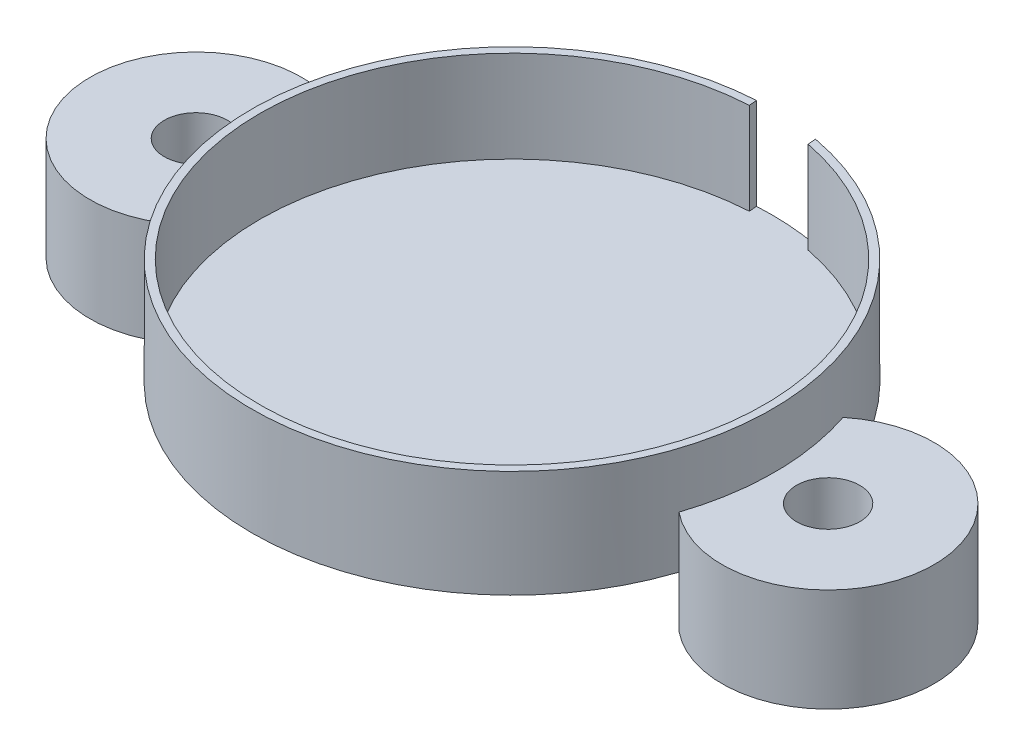
from build123d import *

# Parameters (mm, degrees)
SKETCH1_R                  = 53.2892
BOSS_EXTRUDE1_DEPTH        = 21.971
SKETCH3_R                  = 51.689
CUT_EXTRUDE2_DEPTH         = 18.796
CUT_EXTRUDE7_DEPTH         = 18.796
SKETCH7_R                  = 6.477
BOSS_EXTRUDE3_DEPTH        = 10.16
BOSS_EXTRUDE3_DEPTH_BACK   = 10.9855
BOSS_EXTRUDE3_2_DEPTH      = 10.16
BOSS_EXTRUDE3_2_DEPTH_BACK = 10.9855


with BuildPart() as part:
    # Sketch1 → Boss-Extrude1 (new body)
    with BuildSketch(Plane(origin=(0, 0, 0), x_dir=(1, 0, 0), z_dir=(0, 1, 0))):
        Circle(SKETCH1_R)
    extrude(amount=BOSS_EXTRUDE1_DEPTH)

    # Sketch3 → Cut-Extrude2 (cut)
    with BuildSketch(Plane(origin=(0, 21.971, 0), x_dir=(1, 0, 0), z_dir=(0, 1, 0))):
        Circle(SKETCH3_R)
    extrude(amount=-CUT_EXTRUDE2_DEPTH, mode=Mode.SUBTRACT)

    # Sketch6 → Cut-Extrude7 (cut)
    with BuildSketch(Plane(origin=(0, 21.971, 0), x_dir=(1, 0, 0), z_dir=(0, 1, 0))):
        with BuildLine():
            Line((9.954937367, 50.721316456), (9.791852008, 52.381852496))
            ThreePointArc((9.791852008, 52.381852496), (3.368560686, 53.182625316), (-3.104433229, 53.198696704))
            Line((-3.104433229, 53.198696704), (-2.968977791, 51.603661613))
            ThreePointArc((-2.968977791, 51.603661613), (3.520730186, 51.568955583), (9.954937367, 50.721316456))
        make_face()
    extrude(amount=-CUT_EXTRUDE7_DEPTH, mode=Mode.SUBTRACT)


with BuildPart() as body_2:
    # Sketch7 → Boss-Extrude3 (new body, two sides)
    with BuildSketch(Plane.XZ) as boss_extrude3_sk:
        with BuildLine():
            ThreePointArc((51.021222794, -16.810687504), (86.487, 0), (51.021222794, 16.810687504))
            ThreePointArc((51.021222794, 16.810687504), (53.742938274, 0), (51.021222794, -16.810687504))
        make_face()
        with Locations((64.77, 0)):
            Circle(SKETCH7_R, mode=Mode.SUBTRACT)
    extrude(amount=BOSS_EXTRUDE3_DEPTH)
    extrude(boss_extrude3_sk.sketch, amount=-BOSS_EXTRUDE3_DEPTH_BACK)


with BuildPart() as body_3:
    # Sketch7 → Boss-Extrude3 2 (new body, two sides)
    with BuildSketch(Plane.XZ) as boss_extrude3_2_sk:
        with BuildLine():
            ThreePointArc((-51.021222794, 16.810687504), (-86.487, 0), (-51.021222794, -16.810687504))
            ThreePointArc((-51.021222794, -16.810687504), (-53.742938274, 0), (-51.021222794, 16.810687504))
        make_face()
        with Locations((-64.77, 0)):
            Circle(SKETCH7_R, mode=Mode.SUBTRACT)
    extrude(amount=BOSS_EXTRUDE3_2_DEPTH)
    extrude(boss_extrude3_2_sk.sketch, amount=-BOSS_EXTRUDE3_2_DEPTH_BACK)


solid = Compound([part.part, body_2.part, body_3.part])
